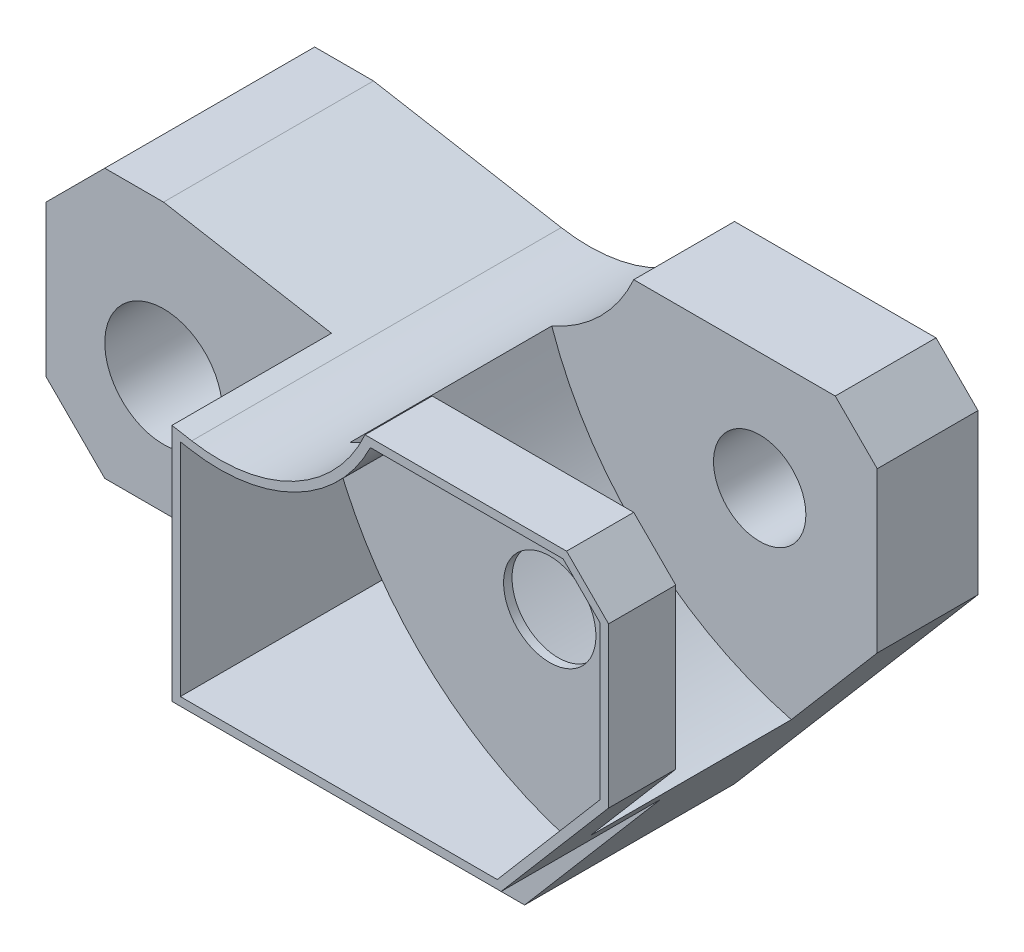
from build123d import *

# Parameters (mm, degrees)
ESQUISSE1_R             = 7
BOSS_EXTRU_1_DEPTH      = 44
ESQUISSE1_4_R           = 7
ENL_V_MAT_EXTRU_1_DEPTH = 19
ENL_V_START             = -8
ESQUISSE1_5_R           = 5.5
ENL_V_MAT_EXTRU_2_DEPTH = 24
ESQUISSE1_7_R           = 5.5
ENL_V_MAT_EXTRU_3_DEPTH = 93.460802506
ENL_V_MAT_EXTRU_4_DEPTH = 32
ESQUISSE1_12_R          = 5.5
ENL_V_MAT_EXTRU_5_DEPTH = 7


with BuildPart() as part:
    # Esquisse1 → Boss.-Extru.1 (new body)
    with BuildSketch(Plane.XY):
        with BuildLine():
            Line((0, 0), (29, 34))
            Line((29, 34), (29, 53))
            Line((29, 53), (24, 58))
            Line((24, 58), (0, 58))
            ThreePointArc((0, 58), (-8.438901294, 48.982044142), (-20.638619164, 47.057085233))
            Line((-20.638619164, 47.057085233), (-43, 51))
            Line((-43, 51), (-50, 51))
            Line((-50, 51), (-57, 44))
            Line((-57, 44), (-57, 26))
            Line((-57, 26), (-50, 19))
            Line((-50, 19), (-17.424461089, 19))
            ThreePointArc((-17.424461089, 19), (-14.159225308, 17.786586232), (-12.478822347, 14.735294118))
            ThreePointArc((-12.478822347, 14.735294118), (-10.141992144, 6.884327939), (-5.703019947, 0))
            Line((-5.703019947, 0), (0, 0))
        make_face()
        with Locations((-43, 33)):
            Circle(ESQUISSE1_R, mode=Mode.SUBTRACT)
    extrude(amount=-BOSS_EXTRU_1_DEPTH)

    # Esquisse1_4 → Enl_v. mat.-Extru.1 (cut)
    # profile 1 of 2: a face of its own
    with BuildSketch(Plane.XY):
        with BuildLine():
            Line((-5.703019947, 0), (0, 0))
            Line((0, 0), (16.205882353, 19))
            Line((16.205882353, 19), (-17.424461089, 19))
            ThreePointArc((-17.424461089, 19), (-14.159225308, 17.786586232), (-12.478822347, 14.735294118))
            ThreePointArc((-12.478822347, 14.735294118), (-10.141992144, 6.884327939), (-5.703019947, 0))
        make_face()
    # profile 2 of 2: a face of its own
    with BuildSketch(Plane.XY):
        Polygon((-50, 19), (-23, 19), (-23, 47.473460386), (-43, 51), (-50, 51), (-57, 44), (-57, 26), align=None)
        with Locations((-43, 33)):
            Circle(ESQUISSE1_4_R, mode=Mode.SUBTRACT)
    extrude(amount=-ENL_V_MAT_EXTRU_1_DEPTH, mode=Mode.SUBTRACT)

    # Esquisse1_5 → Enl_v. mat.-Extru.2 (cut)
    with BuildSketch(Plane.XY.offset(ENL_V_START)):
        with BuildLine():
            Line((18.764705882, 22), (29, 34))
            Line((29, 34), (29, 53))
            Line((29, 53), (24, 58))
            Line((24, 58), (0, 58))
            ThreePointArc((0, 58), (-3.978755657, 52.259333621), (-9.763063451, 48.344294617))
            ThreePointArc((-9.763063451, 48.344294617), (1.184262982, 31.580705229), (18.764705882, 22))
        make_face()
        with Locations((15, 44)):
            Circle(ESQUISSE1_5_R, mode=Mode.SUBTRACT)
    extrude(amount=-ENL_V_MAT_EXTRU_2_DEPTH, mode=Mode.SUBTRACT)

    # Esquisse1_7 → Enl_v. mat.-Extru.3 (cut, through all)
    with BuildSketch(Plane.XY):
        with Locations((15, 44)):
            Circle(ESQUISSE1_7_R)
    extrude(amount=-ENL_V_MAT_EXTRU_3_DEPTH, mode=Mode.SUBTRACT)

    # Esquisse1_11 → Enl_v. mat.-Extru.4 (cut)
    with BuildSketch(Plane.XY):
        with BuildLine():
            Line((15.744476296, 20), (16.986847747, 21.456573425))
            ThreePointArc((16.986847747, 21.456573425), (0.310181683, 31.027872638), (-10.353317057, 47.028208705))
            ThreePointArc((-10.353317057, 47.028208705), (-15.518923584, 45.851449437), (-20.812267342, 46.07227748))
            Line((-20.812267342, 46.07227748), (-22, 46.281706793))
            Line((-22, 46.281706793), (-22, 20))
            Line((-22, 20), (-17.424461089, 20))
            Line((-17.424461089, 20), (15.744476296, 20))
        make_face()
    extrude(amount=-ENL_V_MAT_EXTRU_4_DEPTH, mode=Mode.SUBTRACT)

    # Esquisse1_12 → Enl_v. mat.-Extru.5 (cut)
    with BuildSketch(Plane.XY):
        with BuildLine():
            ThreePointArc((0.636084685, 57), (-3.899559801, 50.957177308), (-10.353317057, 47.028208705))
            ThreePointArc((-10.353317057, 47.028208705), (0.310181683, 31.027872638), (16.986847747, 21.456573425))
            Line((16.986847747, 21.456573425), (28, 34.368545033))
            Line((28, 34.368545033), (28, 52.585786438))
            Line((28, 52.585786438), (23.585786438, 57))
            Line((23.585786438, 57), (0.636084685, 57))
        make_face()
        with Locations((15, 44)):
            Circle(ESQUISSE1_12_R, mode=Mode.SUBTRACT)
    extrude(amount=-ENL_V_MAT_EXTRU_5_DEPTH, mode=Mode.SUBTRACT)


solid = part.part
